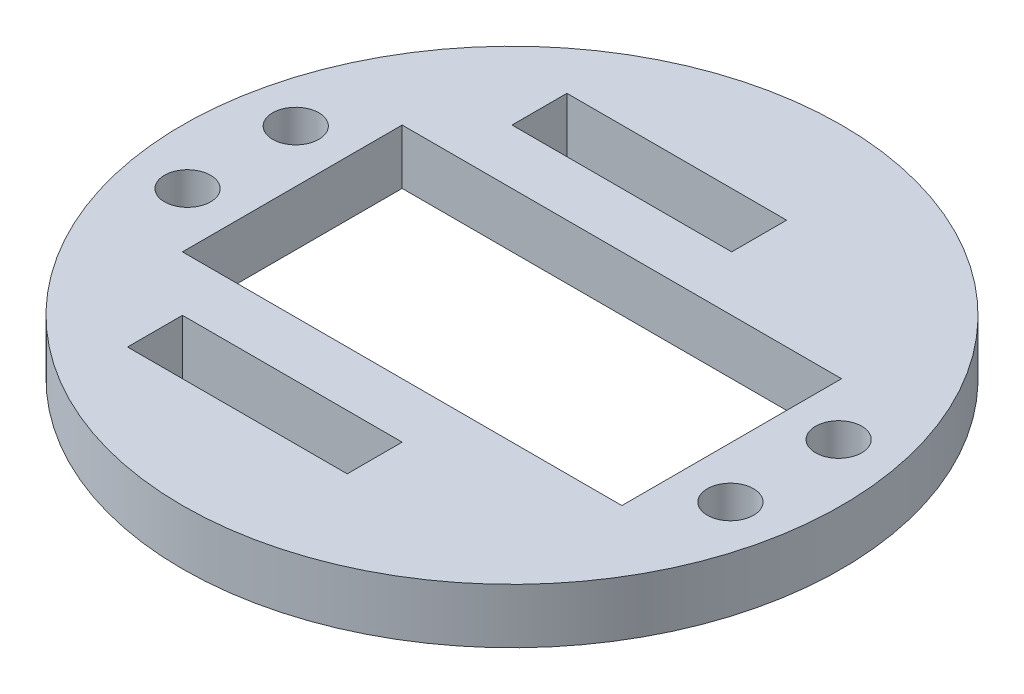
from build123d import *

# Parameters (mm, degrees)
SKETCH2_R           = 30
BOSS_EXTRUDE1_DEPTH = 5
SKETCH3_W           = 40
SKETCH3_H           = 20
CUT_EXTRUDE1_DEPTH  = 6
SKETCH4_W           = 20
SKETCH4_H           = 5
CUT_EXTRUDE2_DEPTH  = 10
SKETCH5_R           = 2.1
CUT_EXTRUDE3_DEPTH  = 6


with BuildPart() as part:
    # Sketch2 → Boss-Extrude1 (new body)
    with BuildSketch(Plane(origin=(0, 0, 0), x_dir=(1, 0, 0), z_dir=(0, 1, 0))):
        Circle(SKETCH2_R)
    extrude(amount=BOSS_EXTRUDE1_DEPTH)

    # Sketch3 → Cut-Extrude1 (cut, through all)
    with BuildSketch(Plane(origin=(0, 5, 0), x_dir=(1, 0, 0), z_dir=(0, 1, 0))):
        Rectangle(SKETCH3_W, SKETCH3_H)
    extrude(amount=-CUT_EXTRUDE1_DEPTH, mode=Mode.SUBTRACT)

    # Sketch4 → Cut-Extrude2 (cut)
    with BuildSketch(Plane(origin=(0, 5, 0), x_dir=(1, 0, 0), z_dir=(0, 1, 0))):
        with Locations((-5, 17.5)):
            Rectangle(SKETCH4_W, SKETCH4_H)
        with Locations((-5, -17.5)):
            Rectangle(SKETCH4_W, SKETCH4_H)
    extrude(amount=-CUT_EXTRUDE2_DEPTH, mode=Mode.SUBTRACT)

    # Sketch5 → Cut-Extrude3 (cut, through all)
    with BuildSketch(Plane.XZ):
        with Locations((-24.761145618, -5.075)):
            Circle(SKETCH5_R)
        with Locations((-24.761145618, 4.775)):
            Circle(SKETCH5_R)
        with Locations((24.661145618, 4.775)):
            Circle(SKETCH5_R)
        with Locations((24.661145618, -5.075)):
            Circle(SKETCH5_R)
    extrude(amount=-CUT_EXTRUDE3_DEPTH, mode=Mode.SUBTRACT)


solid = part.part
